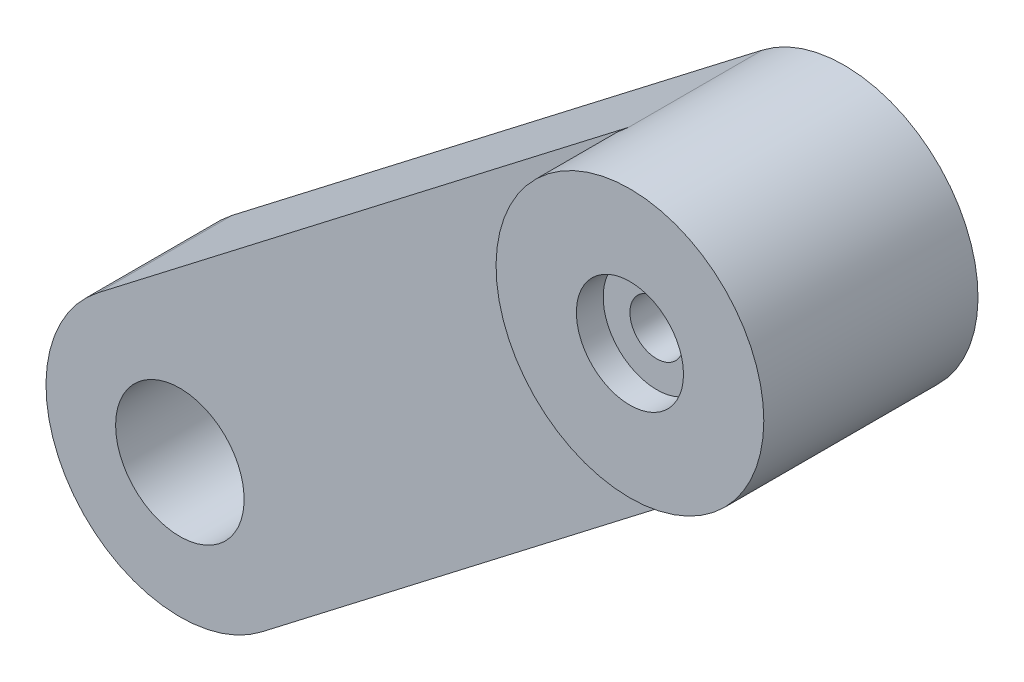
from build123d import *

# Parameters (mm, degrees)
SKETCH1_R           = 2.4
BOSS_EXTRUDE1_DEPTH = 5
SKETCH2_R           = 2.4
CUT_EXTRUDE1_DEPTH  = 5
CUT_EXTRUDE2_DEPTH  = 1
SKETCH5_R           = 5
SKETCH5_R_2         = 1
BOSS_EXTRUDE2_DEPTH = 3
SKETCH6_R           = 2
CUT_EXTRUDE3_DEPTH  = 1


with BuildPart() as part:
    # Sketch1 → Boss-Extrude1 (new body)
    with BuildSketch(Plane(origin=(0, 0, 0), x_dir=(0.999757303, -0.022030336, 0), z_dir=(0, 0, 1))):
        with BuildLine():
            Line((-49.372163993, 87.590629426), (-29.904437649, 103.275259833))
            ThreePointArc((-29.904437649, 103.275259833), (-22.873966299, 102.518640646), (-23.630585486, 95.488169295))
            Line((-23.630585486, 95.488169295), (-43.09831183, 79.803538889))
            ThreePointArc((-43.09831183, 79.803538889), (-50.12878318, 80.560158076), (-49.372163993, 87.590629426))
        make_face()
        with Locations((-26.767511567, 99.381714564)):
            Circle(SKETCH1_R, mode=Mode.SUBTRACT)
    extrude(amount=BOSS_EXTRUDE1_DEPTH)

    # Sketch2 → Cut-Extrude1 (cut)
    with BuildSketch(Plane(origin=(0, 0, 0), x_dir=(-1, 0, 0), z_dir=(0, 0, -1))):
        with Locations((44.380141864, 84.695348924)):
            Circle(SKETCH2_R)
    extrude(amount=-CUT_EXTRUDE1_DEPTH, mode=Mode.SUBTRACT)

    # Sketch4 → Cut-Extrude2 (cut)
    with BuildSketch(Plane(origin=(0, 0, 0), x_dir=(-1, 0, 0), z_dir=(0, 0, -1))):
        Polygon((38.237095204, 87.532175923), (40.067328392, 89.909200633), (41.210775583, 87.135659842), align=None)
    extrude(amount=-CUT_EXTRUDE2_DEPTH, mode=Mode.SUBTRACT)

    # Sketch5 → Boss-Extrude2 (add)
    with BuildSketch(Plane.XY.offset(5)):
        with Locations((-24.571602608, 99.947292162)):
            Circle(SKETCH5_R)
        with Locations((-24.571602608, 99.947292162)):
            Circle(SKETCH5_R_2, mode=Mode.SUBTRACT)
    extrude(amount=BOSS_EXTRUDE2_DEPTH)

    # Sketch6 → Cut-Extrude3 (cut)
    with BuildSketch(Plane.XY.offset(8)):
        with Locations((-24.571602608, 99.947292162)):
            Circle(SKETCH6_R)
    extrude(amount=-CUT_EXTRUDE3_DEPTH, mode=Mode.SUBTRACT)


solid = part.part
